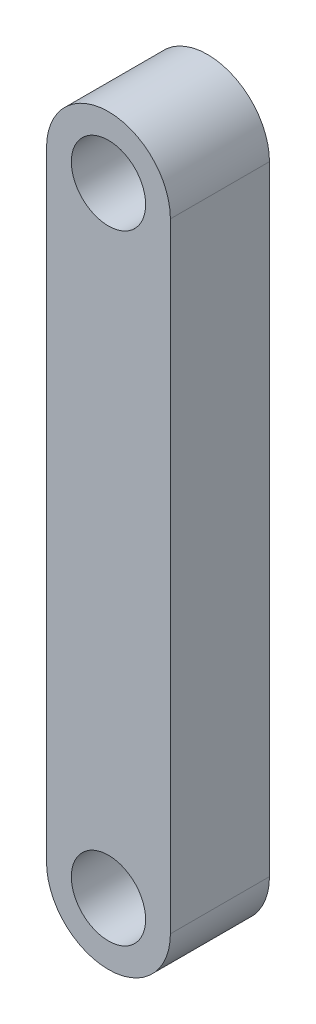
from build123d import *

# Parameters (mm, degrees)
SKETCH_1_R      = 1.5
EXTRUDE_1_DEPTH = 4


with BuildPart() as part:
    # 草图1 → 凸台-拉伸1 (new body)
    with BuildSketch(Plane.XY):
        with BuildLine():
            Line((-2.5, -12.5), (-2.5, 12.5))
            ThreePointArc((-2.5, 12.5), (0, 15), (2.5, 12.5))
            Line((2.5, 12.5), (2.5, -12.5))
            ThreePointArc((2.5, -12.5), (0, -15), (-2.5, -12.5))
        make_face()
        with Locations((0, 12.5)):
            Circle(SKETCH_1_R, mode=Mode.SUBTRACT)
        with Locations((0, -12.5)):
            Circle(SKETCH_1_R, mode=Mode.SUBTRACT)
    extrude(amount=EXTRUDE_1_DEPTH)


solid = part.part
